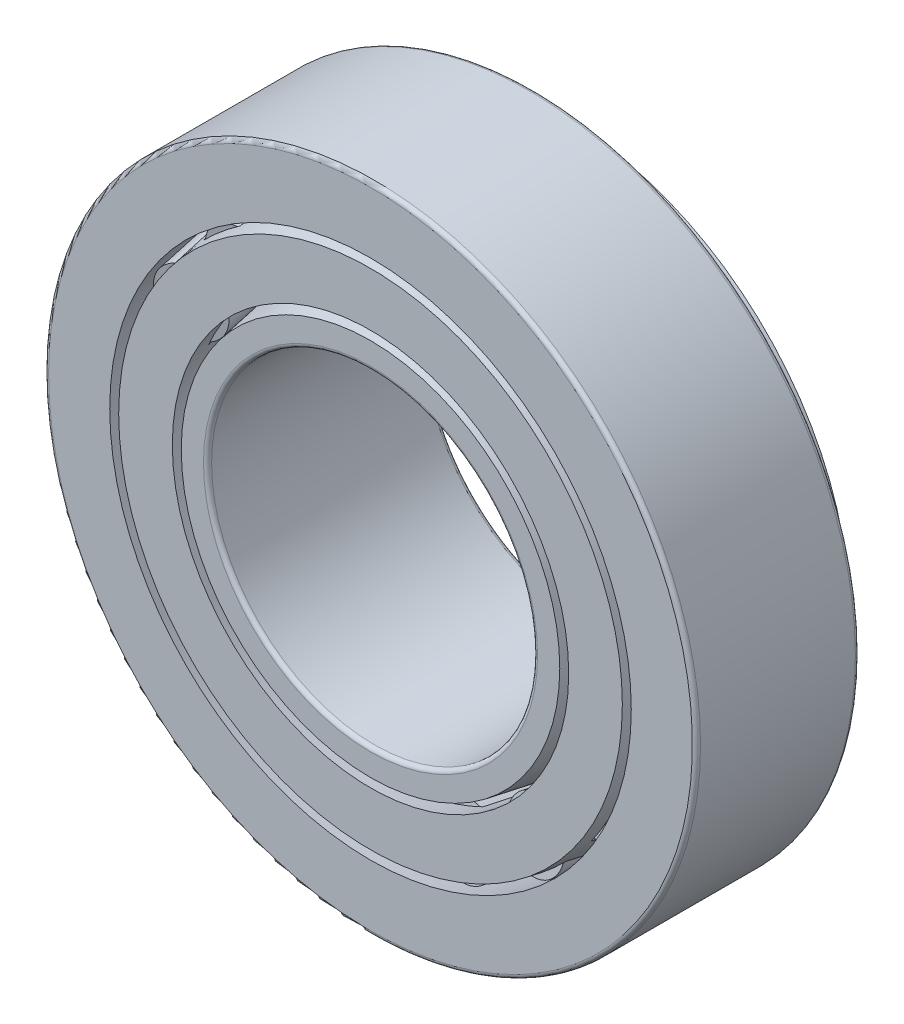
from build123d import *

# Parameters (mm, degrees)
CIRPATTERN1_COUNT = 18
CIRPATTERN2_COUNT = 18
FILLET1_R         = 0.47625
FILLET2_R         = 0.47625


with BuildPart() as part:
    # Sketch1 → Revolve1 (revolve)
    with BuildSketch(Plane(origin=(0, 0, 0), x_dir=(0, 0, -1), z_dir=(1, 0, 0))):
        Polygon((-12.8984375, 38.1), (6.1515625, 38.1), (6.1515625, 33.839028982), (-12.8984375, 30.48), align=None)
    revolve(axis=Axis((0, 0, 12.8984375), (0, 0, -1)))

    # Fillet1
    fillet1_edges = [part.edges().sort_by_distance(p)[0] for p in [
        (0, -38.1, -6.1515625),
        (0, -38.1, 12.8984375),
    ]]
    fillet(fillet1_edges, radius=FILLET1_R)


with BuildPart() as body_2:
    # Sketch5 → Revolve4 (revolve)
    with BuildSketch(Plane(origin=(0, 0, 0), x_dir=(0, 0, -1), z_dir=(1, 0, 0))):
        Polygon((12.8984375, 26.67), (-12.8984375, 22.12131492), (-12.8984375, 19.05), (12.8984375, 19.05), align=None)
    revolve(axis=Axis((0, 0, 12.8984375), (0, 0, -1)))

    # Fillet2
    fillet2_edges = [body_2.edges().sort_by_distance(p)[0] for p in [
        (0, -19.05, -12.8984375),
        (0, -19.05, 12.8984375),
    ]]
    fillet(fillet2_edges, radius=FILLET2_R)


with BuildPart() as body_3:
    # Sketch2 → Revolve2 (revolve)
    with BuildSketch(Plane(origin=(0, 0, 0), x_dir=(0, 0, -1), z_dir=(1, 0, 0))):
        Polygon((-12.8984375, 29.435164365), (-12.8984375, 23.166150555), (6.1515625, 26.525179537), (10.735385083, 27.333431133), (9.663320582, 33.413411047), (6.1515625, 32.794193347), align=None)
    revolve(axis=Axis((0, 0, 12.8984375), (0, 0, -1)))

    # Sketch3 → Cut-Revolve1 (revolve, cut)
    with BuildSketch(Plane(origin=(0, 0, 0), x_dir=(0, 0, -1), z_dir=(1, 0, 0))):
        Polygon((-10.754308498, 26.678725253), (-11.469018165, 30.732045195), (5.436852833, 33.713006385), (6.1515625, 29.659686442), align=None)
    cut_revolve1 = revolve(axis=Axis((0, 26.30065746, 12.8984375), (0, 0.1736481776669246, -0.9848077530122091)), mode=Mode.SUBTRACT)

    # CirPattern1: Cut-Revolve1 ×18 about axis
    cirpattern1_axis = Axis((0, 0, -12.8984375), (0, 0, 1))
    for i in range(1, CIRPATTERN1_COUNT):
        add(cut_revolve1.rotate(cirpattern1_axis, i * 360 / CIRPATTERN1_COUNT), mode=Mode.SUBTRACT)


with BuildPart() as body_4:
    # Sketch4 → Revolve3 (revolve)
    with BuildSketch(Plane(origin=(0, 0, 0), x_dir=(0, 0, -1), z_dir=(1, 0, 0))):
        Polygon((-11.424911528, 30.481904026), (5.48095947, 33.462865216), (6.1515625, 29.659686442), (-10.754308498, 26.678725253), align=None)
    revolve(axis=Axis((0, 26.30065746, 12.8984375), (0, 0.1736481776669246, -0.9848077530122091)))


with BuildPart() as cirpattern2_1:
    # CirPattern2: pattern copy
    add(body_4.part.rotate(Axis((0, 0, -12.8984375), (0, 0, 1)), 1 * 360 / CIRPATTERN2_COUNT))


with BuildPart() as cirpattern2_2:
    # CirPattern2: pattern copy
    add(body_4.part.rotate(Axis((0, 0, -12.8984375), (0, 0, 1)), 2 * 360 / CIRPATTERN2_COUNT))


with BuildPart() as cirpattern2_3:
    # CirPattern2: pattern copy
    add(body_4.part.rotate(Axis((0, 0, -12.8984375), (0, 0, 1)), 3 * 360 / CIRPATTERN2_COUNT))


with BuildPart() as cirpattern2_4:
    # CirPattern2: pattern copy
    add(body_4.part.rotate(Axis((0, 0, -12.8984375), (0, 0, 1)), 4 * 360 / CIRPATTERN2_COUNT))


with BuildPart() as cirpattern2_5:
    # CirPattern2: pattern copy
    add(body_4.part.rotate(Axis((0, 0, -12.8984375), (0, 0, 1)), 5 * 360 / CIRPATTERN2_COUNT))


with BuildPart() as cirpattern2_6:
    # CirPattern2: pattern copy
    add(body_4.part.rotate(Axis((0, 0, -12.8984375), (0, 0, 1)), 6 * 360 / CIRPATTERN2_COUNT))


with BuildPart() as cirpattern2_7:
    # CirPattern2: pattern copy
    add(body_4.part.rotate(Axis((0, 0, -12.8984375), (0, 0, 1)), 7 * 360 / CIRPATTERN2_COUNT))


with BuildPart() as cirpattern2_8:
    # CirPattern2: pattern copy
    add(body_4.part.rotate(Axis((0, 0, -12.8984375), (0, 0, 1)), 8 * 360 / CIRPATTERN2_COUNT))


with BuildPart() as cirpattern2_9:
    # CirPattern2: pattern copy
    add(body_4.part.rotate(Axis((0, 0, -12.8984375), (0, 0, 1)), 9 * 360 / CIRPATTERN2_COUNT))


with BuildPart() as cirpattern2_10:
    # CirPattern2: pattern copy
    add(body_4.part.rotate(Axis((0, 0, -12.8984375), (0, 0, 1)), 10 * 360 / CIRPATTERN2_COUNT))


with BuildPart() as cirpattern2_11:
    # CirPattern2: pattern copy
    add(body_4.part.rotate(Axis((0, 0, -12.8984375), (0, 0, 1)), 11 * 360 / CIRPATTERN2_COUNT))


with BuildPart() as cirpattern2_12:
    # CirPattern2: pattern copy
    add(body_4.part.rotate(Axis((0, 0, -12.8984375), (0, 0, 1)), 12 * 360 / CIRPATTERN2_COUNT))


with BuildPart() as cirpattern2_13:
    # CirPattern2: pattern copy
    add(body_4.part.rotate(Axis((0, 0, -12.8984375), (0, 0, 1)), 13 * 360 / CIRPATTERN2_COUNT))


with BuildPart() as cirpattern2_14:
    # CirPattern2: pattern copy
    add(body_4.part.rotate(Axis((0, 0, -12.8984375), (0, 0, 1)), 14 * 360 / CIRPATTERN2_COUNT))


with BuildPart() as cirpattern2_15:
    # CirPattern2: pattern copy
    add(body_4.part.rotate(Axis((0, 0, -12.8984375), (0, 0, 1)), 15 * 360 / CIRPATTERN2_COUNT))


with BuildPart() as cirpattern2_16:
    # CirPattern2: pattern copy
    add(body_4.part.rotate(Axis((0, 0, -12.8984375), (0, 0, 1)), 16 * 360 / CIRPATTERN2_COUNT))


with BuildPart() as cirpattern2_17:
    # CirPattern2: pattern copy
    add(body_4.part.rotate(Axis((0, 0, -12.8984375), (0, 0, 1)), 17 * 360 / CIRPATTERN2_COUNT))


solid = Compound([part.part, body_2.part, body_3.part, body_4.part, cirpattern2_1.part, cirpattern2_2.part, cirpattern2_3.part, cirpattern2_4.part, cirpattern2_5.part, cirpattern2_6.part, cirpattern2_7.part, cirpattern2_8.part, cirpattern2_9.part, cirpattern2_10.part, cirpattern2_11.part, cirpattern2_12.part, cirpattern2_13.part, cirpattern2_14.part, cirpattern2_15.part, cirpattern2_16.part, cirpattern2_17.part])
